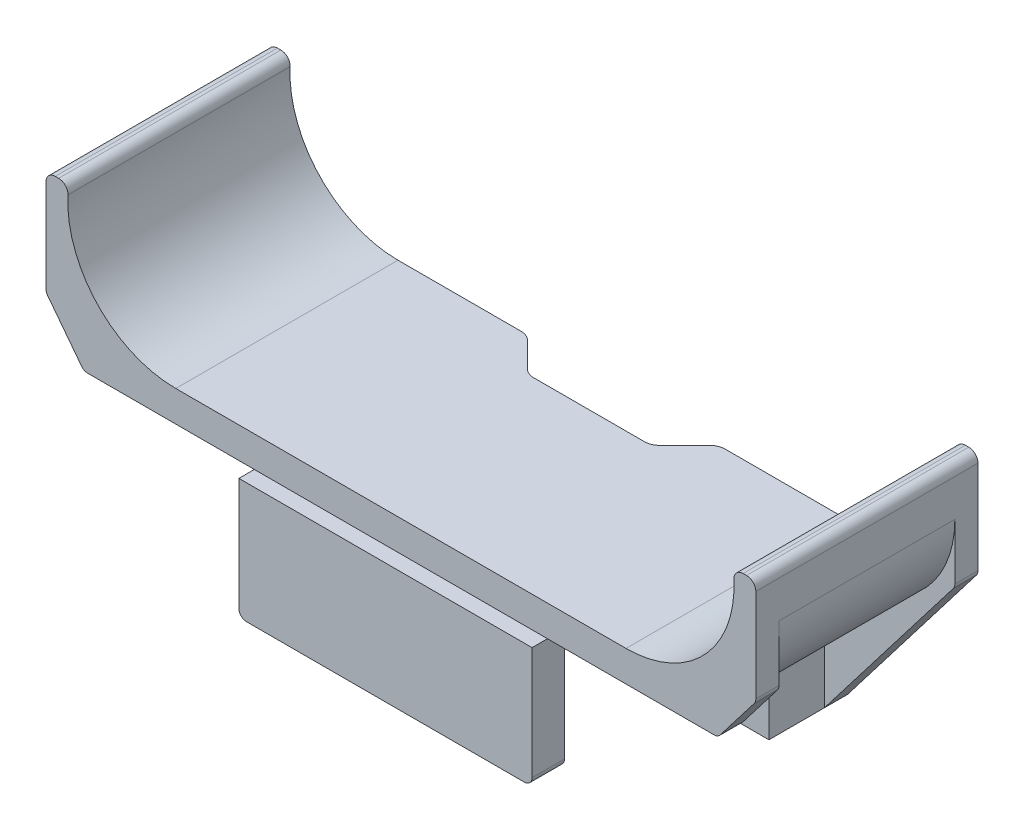
from build123d import *

# Parameters (mm, degrees)
EXTRUDE_1_DEPTH        = 14.4
CUT_EXTRUDE_1_REACH    = 4
EXTRUDE_2_DEPTH        = 1.5
SKETCH_4_W             = 6.8
SKETCH_4_H             = 3.6
EXTRUDE_3_DEPTH        = 7.8
SKETCH_5_W             = 19
SKETCH_5_H             = 2.1
EXTRUDE_4_DEPTH        = 7.8
EXTRUDE_5_DEPTH        = 1.5
HOLE_WIZARD_M3_1_D     = 2.5
HOLE_WIZARD_M3_1_DEPTH = 6.5
HOLE_WIZARD_M3_1_TIP   = 0.751075774
FILLET_1_R             = 0.5
FILLET_2_R             = 1


with BuildPart() as part:
    # 草图1 → 凸台-拉伸1 (new body)
    with BuildSketch(Plane.XY):
        with BuildLine():
            Line((16, 0), (-16, 0))
            ThreePointArc((-16, 0), (-20.949747468, 2.050252532), (-23, 7))
            Line((-23, 7), (-23, 9.4))
            ThreePointArc((-23, 9.4), (-22.824264069, 9.824264069), (-22.4, 10))
            Line((-22.4, 10), (-22.179247695, 10))
            ThreePointArc((-22.179247695, 10), (-21.743961945, 9.812948321), (-21.580079296, 9.368421053))
            ThreePointArc((-21.580079296, 9.368421053), (-19.668115061, 4.182269589), (-14.58978131, 2))
            Line((-14.58978131, 2), (14.58978131, 2))
            ThreePointArc((14.58978131, 2), (19.668115061, 4.182269589), (21.580079296, 9.368421053))
            ThreePointArc((21.580079296, 9.368421053), (21.743961945, 9.812948321), (22.179247695, 10))
            Line((22.179247695, 10), (22.4, 10))
            ThreePointArc((22.4, 10), (22.824264069, 9.824264069), (23, 9.4))
            Line((23, 9.4), (23, 7))
            ThreePointArc((23, 7), (20.949747468, 2.050252532), (16, 0))
        make_face()
    extrude(amount=EXTRUDE_1_DEPTH)

    # 草图2 → 切除-拉伸1 (cut, up to next)
    with BuildSketch(Plane(origin=(0, 2, 0), x_dir=(1, 0, 0), z_dir=(0, 1, 0)), mode=Mode.PRIVATE) as cut_extrude_1_sk1:
        Polygon((4, -2.2), (-4, -2.2), (-6.2, 0), (6.2, 0), align=None)
    cut_extrude_1_tool1 = extrude(cut_extrude_1_sk1.sketch, amount=-CUT_EXTRUDE_1_REACH, mode=Mode.PRIVATE) & part.part
    add(cut_extrude_1_tool1.solids().sort_by_distance((0, 2, 1.020915))[0], mode=Mode.SUBTRACT)

    # 草图3 → 凸台-拉伸2 (add)
    with BuildSketch(Plane.XY):
        Polygon((-7.75, 2), (-7.75, -7.8), (-14.55, -7.8), (-23, 3.2), (-23, 8.2), (-22.047090089, 8.2), (-19.556592195, 2.646086111), (-16.835492645, 2), align=None)
        Polygon((16.835492645, 2), (7.75, 2), (7.75, -7.8), (14.55, -7.8), (23, 3.2), (23, 8.2), (22.047090089, 8.2), (19.556592195, 2.646086111), align=None)
    extrude(amount=EXTRUDE_2_DEPTH)

    # 草图4 → 凸台-拉伸3 (add)
    with BuildSketch(Plane.XZ):
        with Locations((-11.15, 3.3)):
            Rectangle(SKETCH_4_W, SKETCH_4_H)
        with Locations((11.15, 3.3)):
            Rectangle(SKETCH_4_W, SKETCH_4_H)
    extrude(amount=EXTRUDE_3_DEPTH)

    # 草图5 → 凸台-拉伸4 (add)
    with BuildSketch(Plane.XZ):
        with Locations((0, 14.35)):
            Rectangle(SKETCH_5_W, SKETCH_5_H)
    extrude(amount=EXTRUDE_4_DEPTH)

    # 草图6 → 凸台-拉伸5 (add)
    with BuildSketch(Plane.XY.offset(14.4)):
        Polygon((-7.75, 0), (-20.541818182, 0), (-23, 3.2), (-23, 8.2), (-22.047090089, 8.2), (-19.556592195, 2.646086111), (-16.835492645, 2), (-7.75, 2), align=None)
        Polygon((7.75, 0), (20.541818182, 0), (23, 3.2), (23, 8.2), (22.047090089, 8.2), (19.556592195, 2.646086111), (16.835492645, 2), (7.75, 2), align=None)
    extrude(amount=-EXTRUDE_5_DEPTH)

    # M3 螺纹孔1
    with Locations(Plane(origin=(0, -7.8, 0), x_dir=(-1, 0, 0), z_dir=(0, -1, 0))):
        with Locations((-11.15, -2.55), (11.15, -2.55)):
            Hole(HOLE_WIZARD_M3_1_D / 2, depth=HOLE_WIZARD_M3_1_DEPTH)
            with Locations((0, 0, -(HOLE_WIZARD_M3_1_DEPTH + HOLE_WIZARD_M3_1_TIP / 2))):  # 118° drill point
                Cone(0, HOLE_WIZARD_M3_1_D / 2, HOLE_WIZARD_M3_1_TIP, mode=Mode.SUBTRACT)

    # 圆角1
    fillet_1_edges = [part.edges().sort_by_distance(p)[0] for p in [
        (9.5, -7.8, 14.35),
        (-9.5, -7.8, 14.35),
        (-20.541818182, 0, 13.65),
        (-23, 3.2, 13.65),
        (20.541818182, 0, 13.65),
        (23, 3.2, 13.65),
        (-23, 3.2, 0.75),
        (23, 3.2, 0.75),
    ]]
    fillet(fillet_1_edges, radius=FILLET_1_R)

    # 圆角2
    fillet_2_edges = [part.edges().sort_by_distance(p)[0] for p in [
        (-6.2, 1, 0),
        (6.2, 1, 0),
        (4, 1, 2.2),
        (-4, 1, 2.2),
    ]]
    fillet(fillet_2_edges, radius=FILLET_2_R)


solid = part.part
